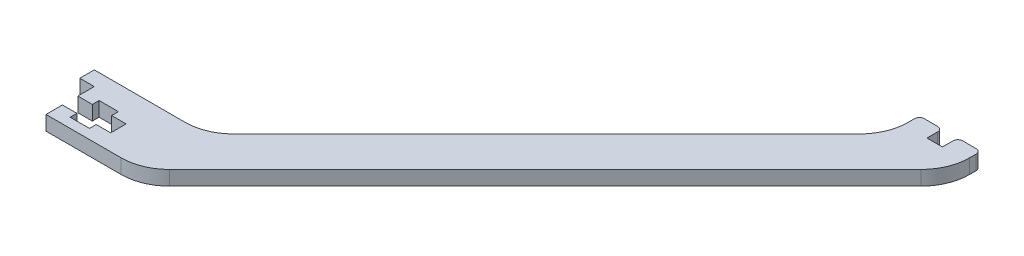
from build123d import *

# Parameters (mm, degrees)
SALIENTE_EXTRUIR1_DEPTH = 3
REDONDEO1_R             = 1


with BuildPart() as part:
    # Croquis1 → Saliente-Extruir1 (new body)
    with BuildSketch(Plane(origin=(0, 0, 0), x_dir=(1, 0, 0), z_dir=(0, 1, 0))):
        with BuildLine():
            Line((10, 3.4), (7, 3.4))
            Line((7, 3.4), (7, 2))
            Line((7, 2), (3, 2))
            Line((3, 2), (3, 3.4))
            Line((3, 3.4), (0, 3.4))
            Line((0, 3.4), (0, 0))
            Line((0, 0), (15.585786438, 0))
            ThreePointArc((15.585786438, 0), (19.412620761, 0.761204675), (22.656854249, 2.928932188))
            Line((22.656854249, 2.928932188), (100.509667992, 80.781745931))
            ThreePointArc((100.509667992, 80.781745931), (102.677395505, 84.025979419), (103.43860018, 87.852813742))
            Line((103.43860018, 87.852813742), (103.43860018, 90.210678119))
            Line((103.43860018, 90.210678119), (98.67360018, 90.210678119))
            Line((98.67360018, 90.210678119), (98.67360018, 87.010678119))
            Line((98.67360018, 87.010678119), (95.47360018, 87.010678119))
            Line((95.47360018, 87.010678119), (95.47360018, 90.210678119))
            Line((95.47360018, 90.210678119), (90.710678119, 90.210678119))
            Line((90.710678119, 90.210678119), (90.710678119, 87.852813742))
            ThreePointArc((90.710678119, 87.852813742), (89.949473444, 84.025979419), (87.781745931, 80.781745931))
            Line((87.781745931, 80.781745931), (22.928932188, 15.928932188))
            ThreePointArc((22.928932188, 15.928932188), (19.6846987, 13.761204675), (15.857864376, 13))
            Line((15.857864376, 13), (-3, 13))
            Line((-3, 13), (-3, 10))
            Line((-3, 10), (0, 10))
            Line((0, 10), (0, 6.6))
            Line((0, 6.6), (3, 6.6))
            Line((3, 6.6), (3, 8))
            Line((3, 8), (7, 8))
            Line((7, 8), (7, 6.6))
            Line((7, 6.6), (10, 6.6))
            Line((10, 6.6), (10, 3.4))
        make_face()
    extrude(amount=SALIENTE_EXTRUIR1_DEPTH)

    # Redondeo1
    redondeo1_edges = [part.edges().sort_by_distance(p)[0] for p in [
        (90.710678119, 1.5, -90.210678119),
        (95.47360018, 1.5, -90.210678119),
        (98.67360018, 1.5, -90.210678119),
        (103.43860018, 1.5, -90.210678119),
    ]]
    fillet(redondeo1_edges, radius=REDONDEO1_R)


solid = part.part
